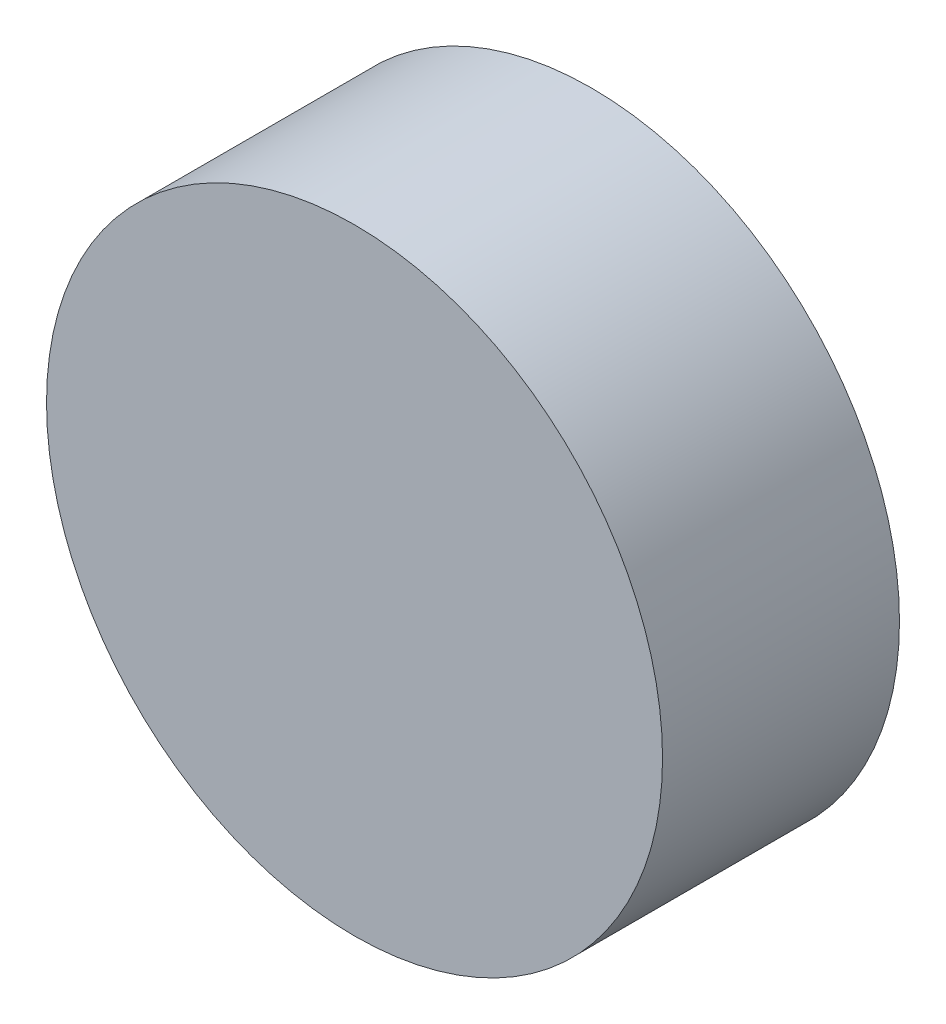
from build123d import *

# Parameters (mm, degrees)
SKETCH1_R           = 33.02
BOSS_EXTRUDE1_DEPTH = 25.4
SKETCH2_R           = 2.54
CUT_EXTRUDE1_DEPTH  = 8.89


with BuildPart() as part:
    # Sketch1 → Boss-Extrude1 (new body)
    with BuildSketch(Plane.XY):
        Circle(SKETCH1_R)
    extrude(amount=-BOSS_EXTRUDE1_DEPTH)

    # Sketch2 → Cut-Extrude1 (cut)
    with BuildSketch(Plane(origin=(0, 0, -25.4), x_dir=(-1, 0, 0), z_dir=(0, 0, -1))):
        Circle(SKETCH2_R)
    extrude(amount=-CUT_EXTRUDE1_DEPTH, mode=Mode.SUBTRACT)


solid = part.part
